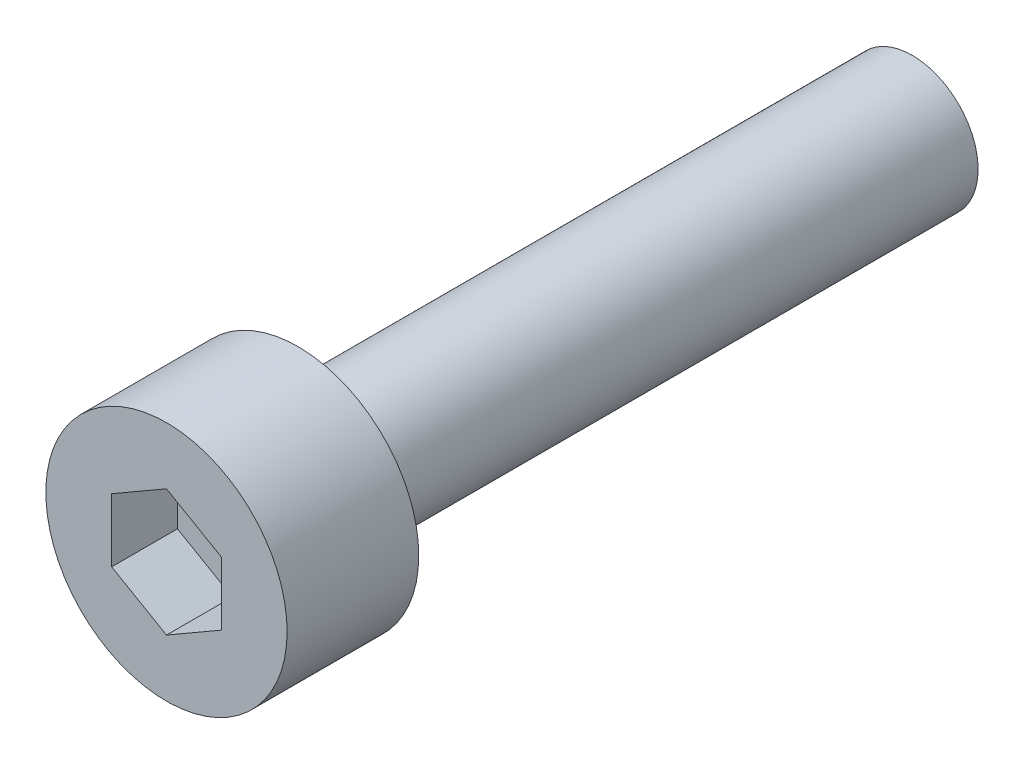
from build123d import *

# Parameters (mm, degrees)
SKETCH_1_R          = 2.75
EXTRUDE_1_DEPTH     = 3
CUT_EXTRUDE_1_DEPTH = 1.5
SKETCH_3_R          = 1.5
EXTRUDE_2_DEPTH     = 14


with BuildPart() as part:
    # 草图1 → 凸台-拉伸1 (new body)
    with BuildSketch(Plane.XY):
        Circle(SKETCH_1_R)
    extrude(amount=EXTRUDE_1_DEPTH)

    # 草图2 → 切除-拉伸1 (cut)
    with BuildSketch(Plane.XY.offset(3)):
        Polygon((0, -1.443375673), (1.25, -0.721687836), (1.25, 0.721687836), (0, 1.443375673), (-1.25, 0.721687836), (-1.25, -0.721687836), align=None)
    extrude(amount=-CUT_EXTRUDE_1_DEPTH, mode=Mode.SUBTRACT)

    # 草图3 → 凸台-拉伸2 (add)
    with BuildSketch(Plane(origin=(0, 0, 0), x_dir=(-1, 0, 0), z_dir=(0, 0, -1))):
        Circle(SKETCH_3_R)
    extrude(amount=EXTRUDE_2_DEPTH)


solid = part.part
